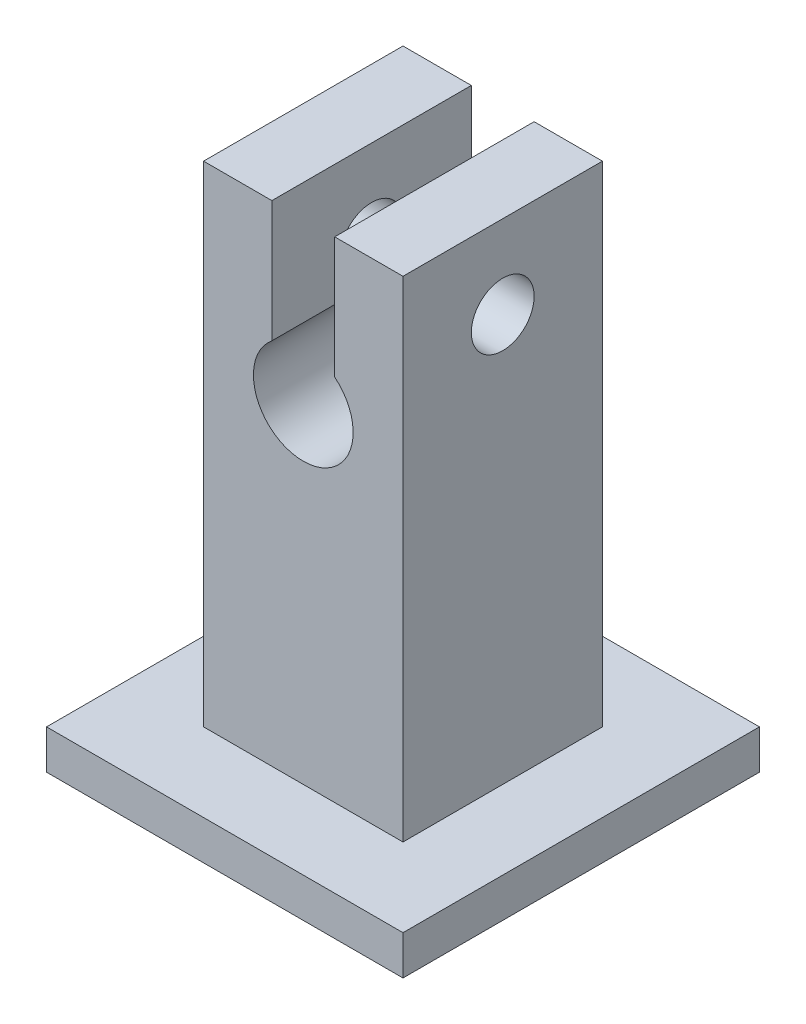
from build123d import *

# Parameters (mm, degrees)
BOSS_EXTRUDE1_DEPTH = 12.7
SKETCH2_W           = 22.7
SKETCH2_H           = 22.7
BOSS_EXTRUDE2_DEPTH = 2.5
SKETCH3_R           = 2
CUT_EXTRUDE1_DEPTH  = 18.7


with BuildPart() as part:
    # Sketch1 → Boss-Extrude1 (new body)
    with BuildSketch(Plane.XY):
        with BuildLine():
            Line((0, 0), (0, 31.2))
            Line((0, 31.2), (-4.35, 31.2))
            Line((-4.35, 31.2), (-4.35, 23.465892333))
            ThreePointArc((-4.35, 23.465892333), (-6.35, 17.825), (-8.35, 23.465892333))
            Line((-8.35, 23.465892333), (-8.35, 31.2))
            Line((-8.35, 31.2), (-12.7, 31.2))
            Line((-12.7, 31.2), (-12.7, 0))
            Line((-12.7, 0), (0, 0))
        make_face()
    extrude(amount=BOSS_EXTRUDE1_DEPTH)

    # Sketch2 → Boss-Extrude2 (add)
    with BuildSketch(Plane.XZ):
        with Locations((-6.35, 6.35)):
            Rectangle(SKETCH2_W, SKETCH2_H)
    extrude(amount=BOSS_EXTRUDE2_DEPTH)

    # Sketch3 → Cut-Extrude1 (cut, through all)
    with BuildSketch(Plane(origin=(0, 0, 0), x_dir=(0, 0, -1), z_dir=(1, 0, 0))):
        with Locations((-6.35, 25.920446167)):
            Circle(SKETCH3_R)
    extrude(amount=-CUT_EXTRUDE1_DEPTH, mode=Mode.SUBTRACT)


solid = part.part
